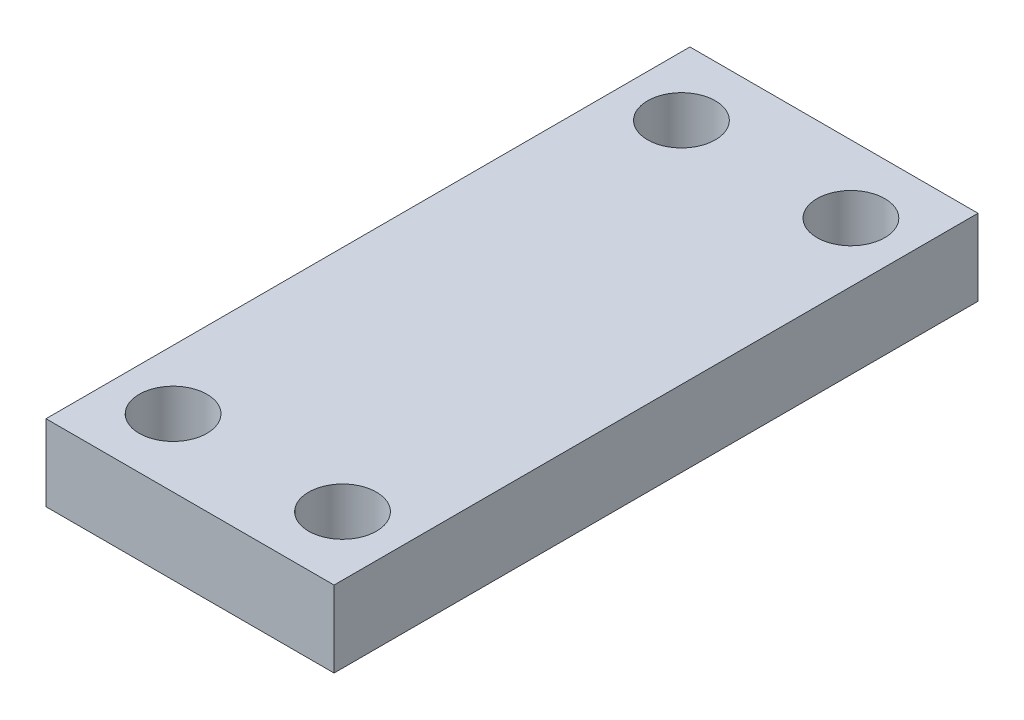
from build123d import *

# Parameters (mm, degrees)
SKETCH1_W           = 17
SKETCH1_H           = 38
BOSS_EXTRUDE1_DEPTH = 4.5
SKETCH1_3_R         = 2
CUT_EXTRUDE1_DEPTH  = 4.5


with BuildPart() as part:
    # Sketch1 → Boss-Extrude1 (new body)
    with BuildSketch(Plane(origin=(0, 0, 0), x_dir=(1, 0, 0), z_dir=(0, 1, 0))):
        Rectangle(SKETCH1_W, SKETCH1_H)
    extrude(amount=BOSS_EXTRUDE1_DEPTH)

    # Sketch1_3 → Cut-Extrude1 (cut)
    with BuildSketch(Plane(origin=(0, 0, 0), x_dir=(1, 0, 0), z_dir=(0, 1, 0))):
        with Locations((-5, 15)):
            Circle(SKETCH1_3_R)
        with Locations((5, 15)):
            Circle(SKETCH1_3_R)
        with Locations((5, -15)):
            Circle(SKETCH1_3_R)
        with Locations((-5, -15)):
            Circle(SKETCH1_3_R)
    extrude(amount=CUT_EXTRUDE1_DEPTH, mode=Mode.SUBTRACT)


solid = part.part
